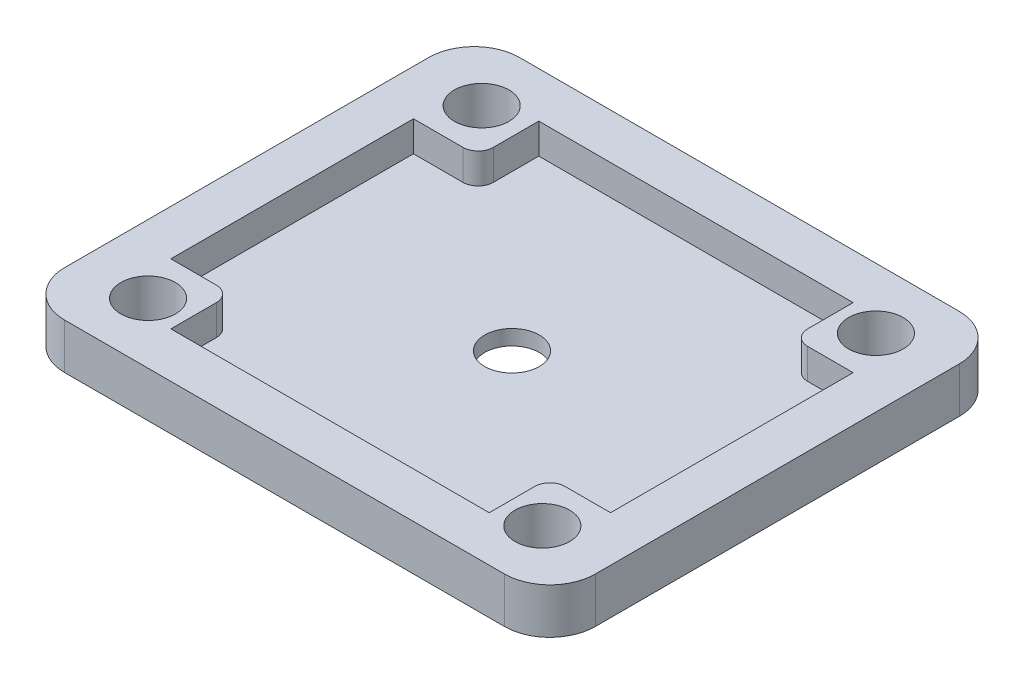
from build123d import *

# Parameters (mm, degrees)
SKETCH1_W            = 35
SKETCH1_H            = 30
BOSS_EXTRUDE1_DEPTH  = 3
SKETCH2_W            = 29
SKETCH2_H            = 24
CUT_EXTRUDE1_DEPTH   = 2
SKETCH5_W            = 4.266255033
SKETCH5_H            = 4
SKETCH5_W_2          = 4
BOSS_EXTRUDE2_DEPTH  = 2
M3_CLEARANCE_HOLE1_D = 3.6
FILLET1_R            = 3
FILLET2_R            = 1


with BuildPart() as part:
    # Sketch1 → Boss-Extrude1 (new body)
    with BuildSketch(Plane(origin=(0, 0, 0), x_dir=(1, 0, 0), z_dir=(0, 1, 0))):
        Rectangle(SKETCH1_W, SKETCH1_H)
    extrude(amount=BOSS_EXTRUDE1_DEPTH)

    # Sketch2 → Cut-Extrude1 (cut)
    with BuildSketch(Plane(origin=(0, 3, 0), x_dir=(1, 0, 0), z_dir=(0, 1, 0))):
        Rectangle(SKETCH2_W, SKETCH2_H)
    extrude(amount=-CUT_EXTRUDE1_DEPTH, mode=Mode.SUBTRACT)

    # Sketch5 → Boss-Extrude2 (add)
    with BuildSketch(Plane(origin=(0, 1, 0), x_dir=(1, 0, 0), z_dir=(0, 1, 0))):
        with Locations((-12.366872483, 10)):
            Rectangle(SKETCH5_W, SKETCH5_H)
        with Locations((12.5, 10)):
            Rectangle(SKETCH5_W_2, SKETCH5_H)
        with Locations((12.5, -10)):
            Rectangle(SKETCH5_W_2, SKETCH5_H)
        with Locations((-12.5, -10)):
            Rectangle(SKETCH5_W_2, SKETCH5_H)
    extrude(amount=BOSS_EXTRUDE2_DEPTH)

    # M3 Clearance Hole1 (through all)
    with Locations(Plane(origin=(0, 3, 0), x_dir=(1, 0, 0), z_dir=(0, 1, 0))):
        with Locations((0, 0), (13, 11), (-13, -11), (-13, 11), (13, -11)):
            Hole(M3_CLEARANCE_HOLE1_D / 2)

    # Fillet1
    fillet1_edges = [part.edges().sort_by_distance(p)[0] for p in [
        (17.5, 1.5, 15),
        (-17.5, 1.5, 15),
        (-17.5, 1.5, -15),
        (17.5, 1.5, -15),
    ]]
    fillet(fillet1_edges, radius=FILLET1_R)

    # Fillet2
    fillet2_edges = [part.edges().sort_by_distance(p)[0] for p in [
        (-10.233744967, 2, -8),
        (10.5, 2, -8),
        (10.5, 2, 8),
        (-10.5, 2, 8),
    ]]
    fillet(fillet2_edges, radius=FILLET2_R)


solid = part.part
